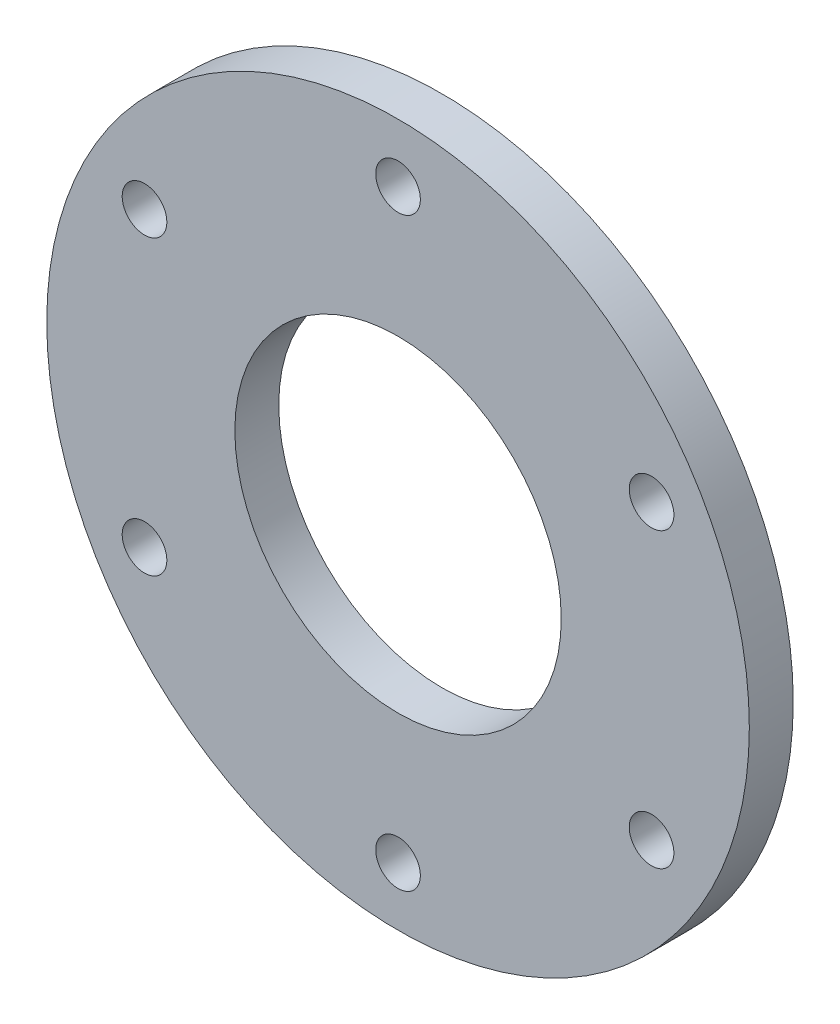
from build123d import *

# Parameters (mm, degrees)
SKETCH_1_R      = 24
SKETCH_1_R_2    = 11.15
SKETCH_1_R_3    = 1.525
EXTRUDE_1_DEPTH = 3


with BuildPart() as part:
    # 草图1 → 凸台-拉伸1 (new body)
    with BuildSketch(Plane.XY):
        Circle(SKETCH_1_R)
        Circle(SKETCH_1_R_2, mode=Mode.SUBTRACT)
        with Locations((0, 20)):
            Circle(SKETCH_1_R_3, mode=Mode.SUBTRACT)
        with Locations((17.320508076, 10)):
            Circle(SKETCH_1_R_3, mode=Mode.SUBTRACT)
        with Locations((17.320508076, -10)):
            Circle(SKETCH_1_R_3, mode=Mode.SUBTRACT)
        with Locations((0, -20)):
            Circle(SKETCH_1_R_3, mode=Mode.SUBTRACT)
        with Locations((-17.320508076, -10)):
            Circle(SKETCH_1_R_3, mode=Mode.SUBTRACT)
        with Locations((-17.320508076, 10)):
            Circle(SKETCH_1_R_3, mode=Mode.SUBTRACT)
    extrude(amount=EXTRUDE_1_DEPTH)


solid = part.part
